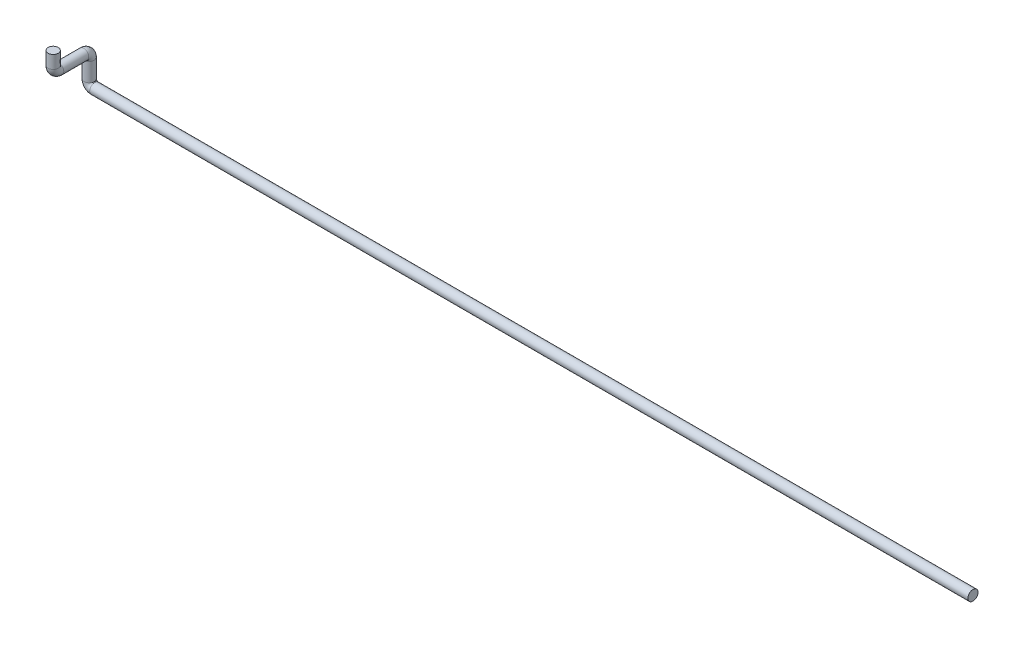
from build123d import *

# Parameters (mm, degrees)
CROQUIS1_R = 13.7


with BuildPart() as part:
    # Barrer1: sweep along a curve in space
    with BuildLine() as barrer1_path:
        Line((0, 0, 0), (-2374, 0, 0))
        ThreePointArc((-2374, 0, 0), (-2384.606601718, 4.393398282, 0), (-2389, 15, 0))
        Line((-2389, 15, 0), (-2389, 65, 0))
        ThreePointArc((-2389, 65, 0), (-2389, 75.606601718, 4.393398282), (-2389, 80, 15))
        Line((-2389, 80, 15), (-2389, 80, 82.5))
        ThreePointArc((-2389, 80, 82.5), (-2389, 84.393398282, 93.106601718), (-2389, 95, 97.5))
        Line((-2389, 95, 97.5), (-2389, 130, 97.5))
    # Croquis1 → Barrer1 (sweep)
    with BuildSketch(Plane(origin=(0, 0, 0), x_dir=(0, 0, -1), z_dir=(1, 0, 0))):
        Circle(CROQUIS1_R)
    sweep(path=barrer1_path.line)


solid = part.part
